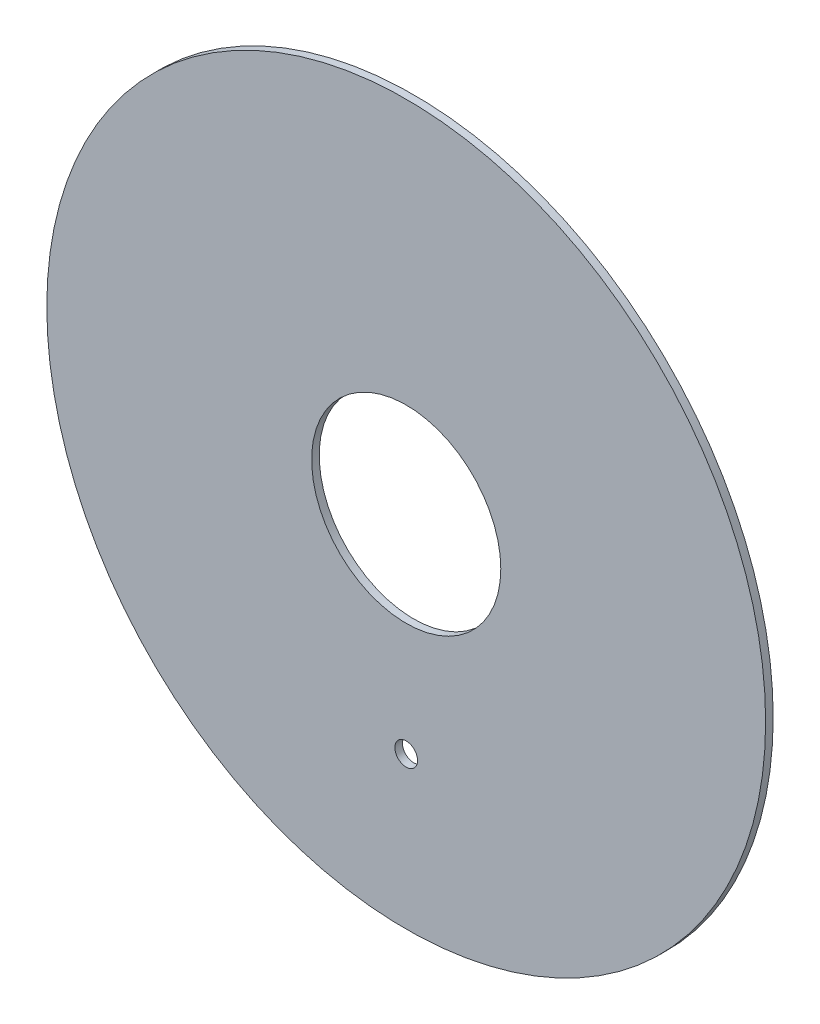
from build123d import *

# Parameters (mm, degrees)
ESBO_O1_R                = 47.5
ESBO_O1_R_2              = 12.5
RESSALTO_EXTRUS_O1_DEPTH = 1
ESBO_O2_R                = 1.5
CORTE_EXTRUS_O1_DEPTH    = 1


with BuildPart() as part:
    # Esboço1 → Ressalto-extrusão1 (new body)
    with BuildSketch(Plane.XY):
        Circle(ESBO_O1_R)
        Circle(ESBO_O1_R_2, mode=Mode.SUBTRACT)
    extrude(amount=RESSALTO_EXTRUS_O1_DEPTH)

    # Esboço2 → Corte-extrusão1 (cut)
    with BuildSketch(Plane.XY.offset(1)):
        with Locations((0, -27.453800689)):
            Circle(ESBO_O2_R)
    extrude(amount=-CORTE_EXTRUS_O1_DEPTH, mode=Mode.SUBTRACT)


solid = part.part
